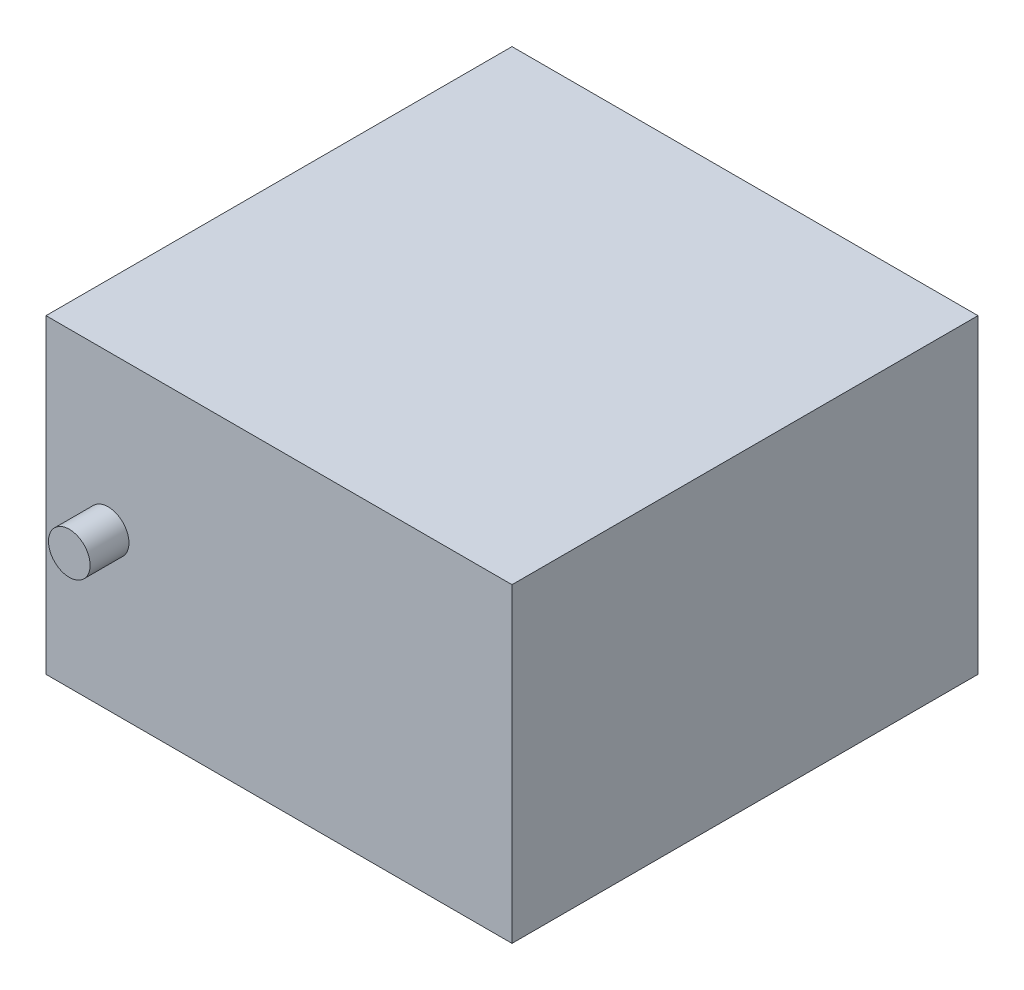
from build123d import *

# Parameters (mm, degrees)
SKETCH1_W           = 40
SKETCH1_H           = 20
BOSS_EXTRUDE1_DEPTH = 40
SKETCH2_R           = 1.340799443
BOSS_EXTRUDE2_DEPTH = 2.5
SKETCH3_W           = 40
SKETCH3_H           = 10
CUT_EXTRUDE1_DEPTH  = 20
SKETCH5_W           = 10
SKETCH5_H           = 30
CUT_EXTRUDE4_DEPTH  = 20


with BuildPart() as part:
    # Sketch1 → Boss-Extrude1 (new body)
    with BuildSketch(Plane.XY):
        with Locations((-12.31884058, 10.869565217)):
            Rectangle(SKETCH1_W, SKETCH1_H)
    extrude(amount=BOSS_EXTRUDE1_DEPTH)

    # Sketch2 → Boss-Extrude2 (add)
    with BuildSketch(Plane.XY.offset(40)):
        with Locations((-28.31884058, 10.869565217)):
            Circle(SKETCH2_R)
    extrude(amount=BOSS_EXTRUDE2_DEPTH)

    # Sketch3 → Cut-Extrude1 (cut)
    with BuildSketch(Plane.XZ.offset(-0.869565217)):
        with Locations((-12.31884058, 5)):
            Rectangle(SKETCH3_W, SKETCH3_H)
    extrude(amount=-CUT_EXTRUDE1_DEPTH, mode=Mode.SUBTRACT)

    # Sketch5 → Cut-Extrude4 (cut)
    with BuildSketch(Plane.XZ.offset(-0.869565217)):
        with Locations((2.68115942, 25)):
            Rectangle(SKETCH5_W, SKETCH5_H)
    extrude(amount=-CUT_EXTRUDE4_DEPTH, mode=Mode.SUBTRACT)


solid = part.part
